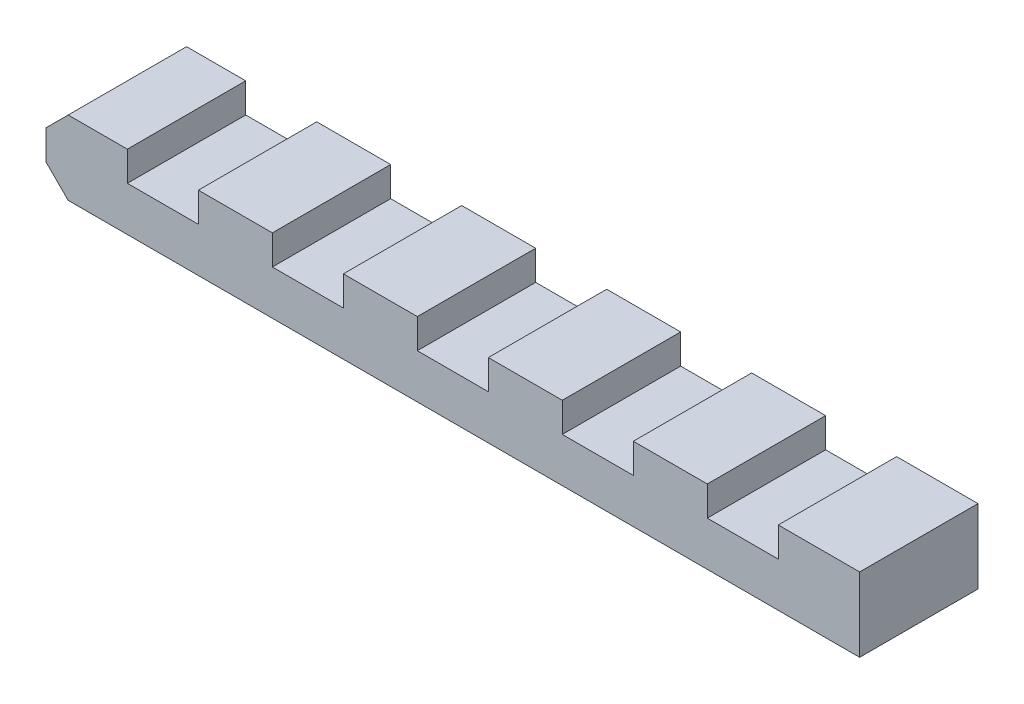
from build123d import *

# Parameters (mm, degrees)
SKETCH_1_W          = 55
SKETCH_1_H          = 8
EXTRUDE_1_DEPTH     = 5
SKETCH_2_W          = 4.8
SKETCH_2_H          = 2
CUT_EXTRUDE_1_DEPTH = 9
CHAMFER_1_SIZE      = 1.5


with BuildPart() as part:
    # 草图1 → 凸台-拉伸1 (new body)
    with BuildSketch(Plane(origin=(0, 0, 0), x_dir=(1, 0, 0), z_dir=(0, 1, 0))):
        Rectangle(SKETCH_1_W, SKETCH_1_H)
    extrude(amount=EXTRUDE_1_DEPTH)

    # 草图2 → 切除-拉伸1 (cut, through all)
    with BuildSketch(Plane.XY.offset(4)):
        with Locations((-19.6, 4)):
            Rectangle(SKETCH_2_W, SKETCH_2_H)
        with Locations((-9.8, 4)):
            Rectangle(SKETCH_2_W, SKETCH_2_H)
        with Locations((0, 4)):
            Rectangle(SKETCH_2_W, SKETCH_2_H)
        with Locations((9.8, 4)):
            Rectangle(SKETCH_2_W, SKETCH_2_H)
        with Locations((19.6, 4)):
            Rectangle(SKETCH_2_W, SKETCH_2_H)
    extrude(amount=-CUT_EXTRUDE_1_DEPTH, mode=Mode.SUBTRACT)

    # 倒角1
    chamfer_1_edges = [part.edges().sort_by_distance(p)[0] for p in [
        (-27.5, 5, 0),
        (-27.5, 0, 0),
    ]]
    chamfer(chamfer_1_edges, length=CHAMFER_1_SIZE)


solid = part.part
